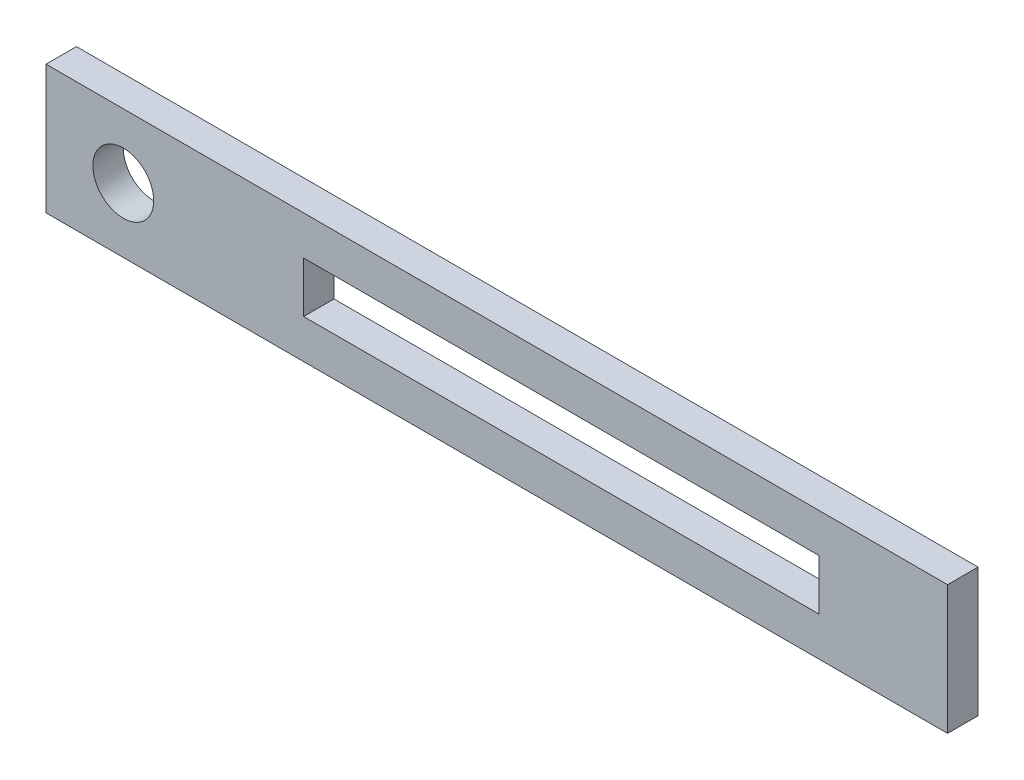
from build123d import *

# Parameters (mm, degrees)
SKETCH1_W           = 88.9
SKETCH1_H           = 12.7
SKETCH1_R           = 3
SKETCH1_W_2         = 50.8
SKETCH1_H_2         = 5
BOSS_EXTRUDE1_DEPTH = 1.5


with BuildPart() as part:
    # Sketch1 → Boss-Extrude1 (new body, symmetric)
    with BuildSketch(Plane.XY):
        with Locations((36.83, 0)):
            Rectangle(SKETCH1_W, SKETCH1_H)
        Circle(SKETCH1_R, mode=Mode.SUBTRACT)
        with Locations((43.18, 0)):
            Rectangle(SKETCH1_W_2, SKETCH1_H_2, mode=Mode.SUBTRACT)
    extrude(amount=BOSS_EXTRUDE1_DEPTH, both=True)


solid = part.part
